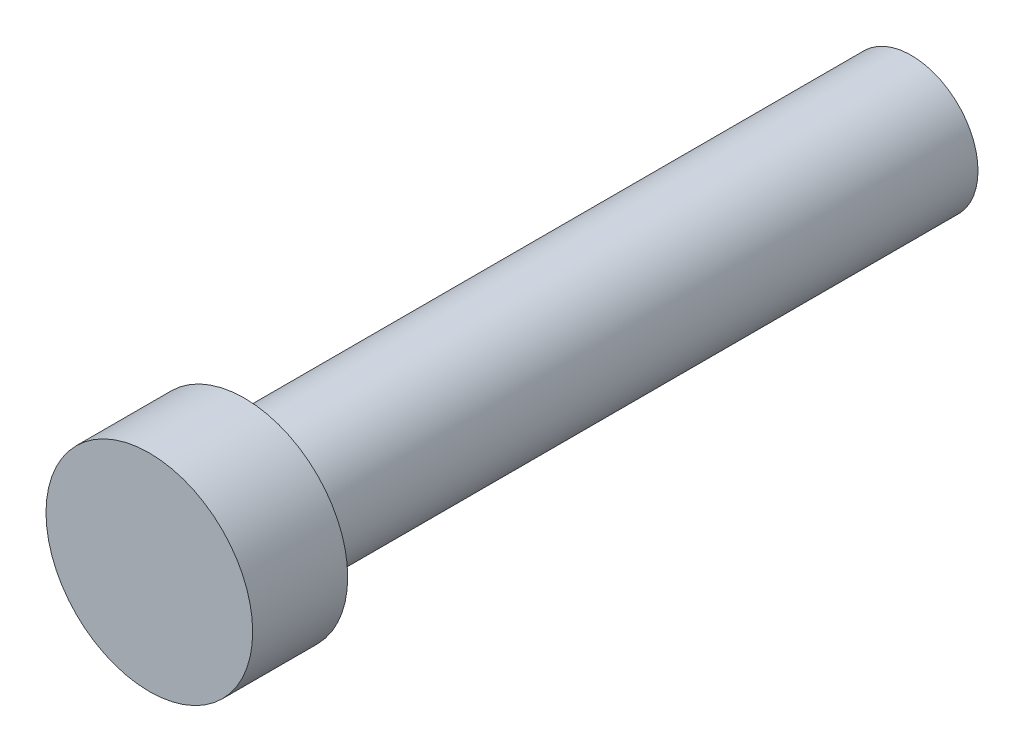
from build123d import *

# Parameters (mm, degrees)
SKETCH1_R           = 4
BOSS_EXTRUDE1_DEPTH = 40
SKETCH2_R           = 6.1976
BOSS_EXTRUDE2_DEPTH = 5.7


with BuildPart() as part:
    # Sketch1 → Boss-Extrude1 (new body)
    with BuildSketch(Plane.XY):
        Circle(SKETCH1_R)
    extrude(amount=BOSS_EXTRUDE1_DEPTH)

    # Sketch2 → Boss-Extrude2 (add)
    with BuildSketch(Plane.XY.offset(40)):
        Circle(SKETCH2_R)
    extrude(amount=BOSS_EXTRUDE2_DEPTH)


solid = part.part
